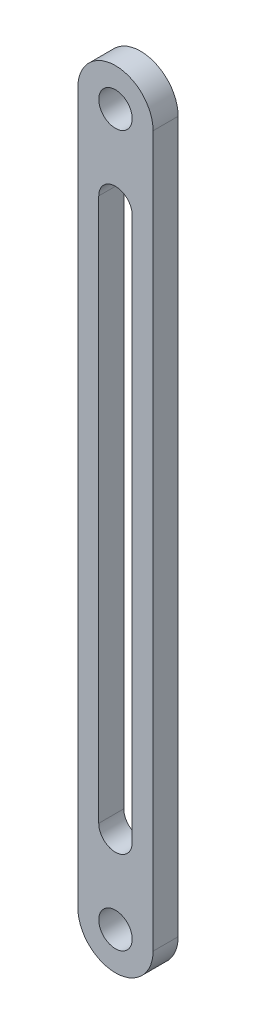
from build123d import *

# Parameters (mm, degrees)
CROQUIS1_R              = 2
SALIENTE_EXTRUIR1_DEPTH = 3


with BuildPart() as part:
    # Croquis1 → Saliente-Extruir1 (new body)
    with BuildSketch(Plane.XY):
        with BuildLine():
            Line((-4.5, 85), (-4.5, 0))
            ThreePointArc((-4.5, 0), (0, -4.5), (4.5, 0))
            Line((4.5, 0), (4.5, 85))
            ThreePointArc((4.5, 85), (0, 89.5), (-4.5, 85))
        make_face()
        with Locations((0, 85)):
            Circle(CROQUIS1_R, mode=Mode.SUBTRACT)
        Circle(CROQUIS1_R, mode=Mode.SUBTRACT)
        with BuildLine():
            Line((-2, 75), (-2, 10))
            ThreePointArc((-2, 10), (0, 8), (2, 10))
            Line((2, 10), (2, 75))
            ThreePointArc((2, 75), (0, 77), (-2, 75))
        make_face(mode=Mode.SUBTRACT)
    extrude(amount=SALIENTE_EXTRUIR1_DEPTH)


solid = part.part
